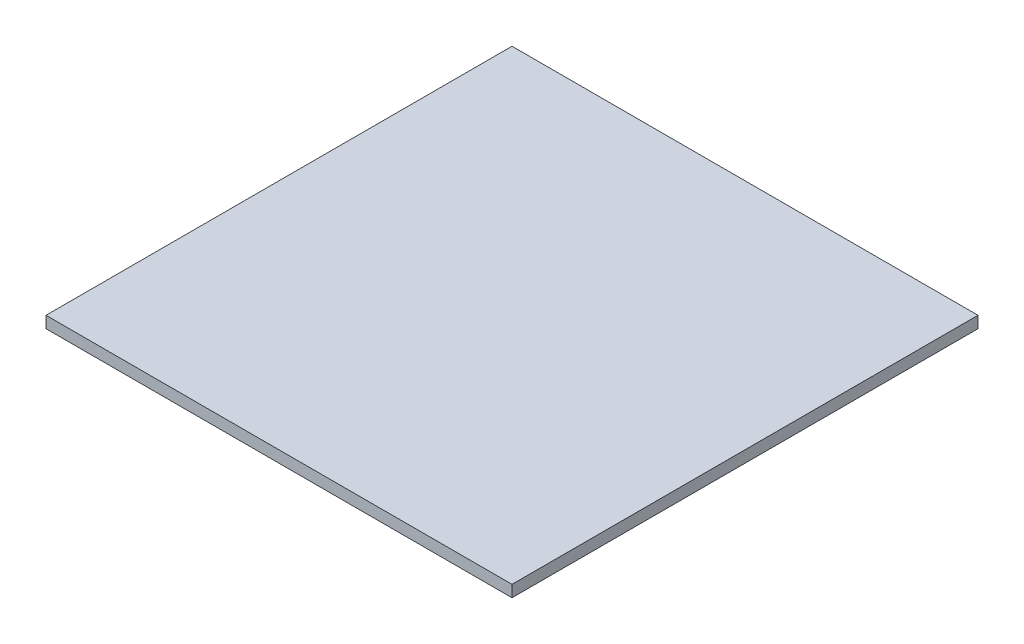
from build123d import *

# Parameters (mm, degrees)
SKETCH1_W           = 120
SKETCH1_H           = 120
BOSS_EXTRUDE1_DEPTH = 3


with BuildPart() as part:
    # Sketch1 → Boss-Extrude1 (new body)
    with BuildSketch(Plane(origin=(0, 0, 0), x_dir=(1, 0, 0), z_dir=(0, 1, 0))):
        with Locations((60, 60)):
            Rectangle(SKETCH1_W, SKETCH1_H)
    extrude(amount=BOSS_EXTRUDE1_DEPTH)


solid = part.part
